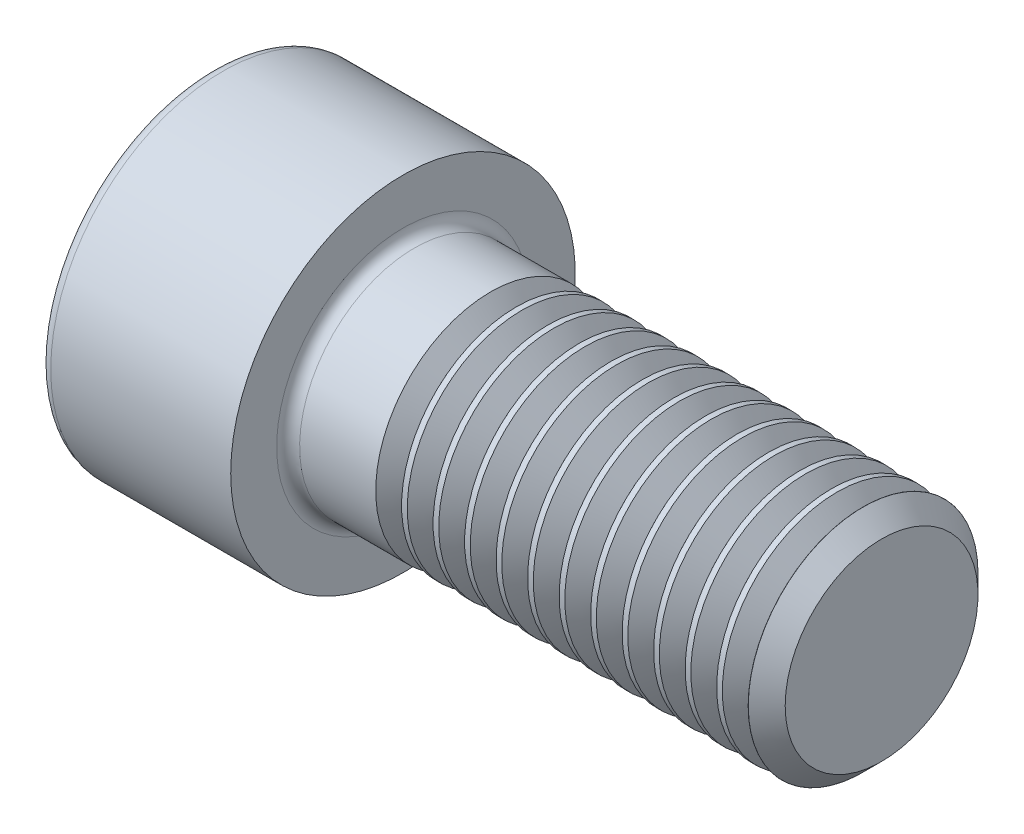
from build123d import *

# Parameters (mm, degrees)
FILLET1_R       = 0.6
FILLET2_R       = 0.6
HEX_2_DEPTH     = 6
THDSCHPAT_COUNT = 12
THDSCHPAT_PITCH = 1.645833333


with BuildPart() as part:
    # BodySke → Base-Revolve (revolve)
    with BuildSketch(Plane.XY):
        Polygon((0, 0), (0, 9), (10, 9), (10, 6), (34.036, 6), (35, 5.036), (35, 0), align=None)
    revolve(axis=Axis((-31.75, 0, 0), (1, 0, 0)))

    # Fillet1
    fillet1_edges = [part.edges().sort_by_distance(p)[0] for p in [
        (10, -6, 0),
    ]]
    fillet(fillet1_edges, radius=FILLET1_R)

    # Fillet2
    fillet2_edges = [part.edges().sort_by_distance(p)[0] for p in [
        (0, -9, 0),
    ]]
    fillet(fillet2_edges, radius=FILLET2_R)

    # Sketch2 → Hex-PreBroach (revolve, cut)
    with BuildSketch(Plane.XY):
        Polygon((0, 5.0575), (6, 5.0575), (8.919948986, 0), (0, 0), align=None)
    revolve(axis=Axis((0, 0, 0), (1, 0, 0)), mode=Mode.SUBTRACT)

    # Sketch3 → Hex 2 (cut)
    with BuildSketch(Plane(origin=(0, 0, 0), x_dir=(0, 0.5, 0.866025404), z_dir=(-1, 0, 0))):
        Polygon((2.919948986, 5.0575), (-2.919948986, 5.0575), (-5.839897973, 0), (-2.919948986, -5.0575), (2.919948986, -5.0575), (5.839897973, 0), align=None)
    extrude(amount=-HEX_2_DEPTH, mode=Mode.SUBTRACT)

    # ThdSchSke → ThreadSchematic (revolve, cut)
    with BuildSketch(Plane.XY):
        Polygon((15.25, -5.036), (14.574999933, -6), (14.574999933, -7.5), (15.925000067, -7.5), (15.925000067, -6), align=None)
    threadschematic = revolve(axis=Axis((-3.175, 0, 0), (1, 0, 0)), mode=Mode.SUBTRACT)

    # ThdSchPat: ThreadSchematic ×12
    with Locations(*[(i * THDSCHPAT_PITCH, 0, 0) for i in range(1, THDSCHPAT_COUNT)]):
        add(threadschematic, mode=Mode.SUBTRACT)


solid = part.part
